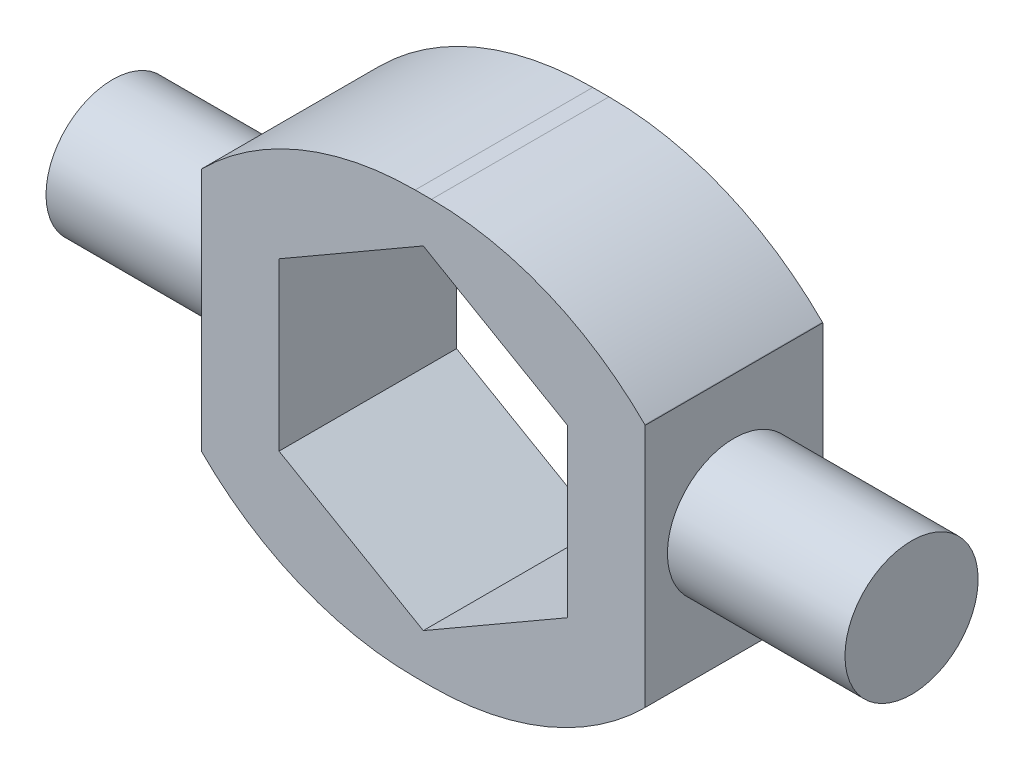
from build123d import *

# Parameters (mm, degrees)
SKETCH1_W           = 63.5
SKETCH1_H           = 60.360264722
BOSS_EXTRUDE1_DEPTH = 25.4
CHAMFER1_SIZE       = 12.7
SKETCH2_R           = 9.525
BOSS_EXTRUDE2_DEPTH = 25.4
FILLET1_R           = 43.18


with BuildPart() as part:
    # Sketch1 → Boss-Extrude1 (new body)
    with BuildSketch(Plane.XY):
        with Locations((31.75, 30.180132361)):
            Rectangle(SKETCH1_W, SKETCH1_H)
        Polygon((11.1125, 42.095198541), (11.1125, 18.26506618), (31.75, 6.35), (52.3875, 18.26506618), (52.3875, 42.095198541), (31.75, 54.010264722), align=None, mode=Mode.SUBTRACT)
    extrude(amount=BOSS_EXTRUDE1_DEPTH)

    # Chamfer1
    chamfer1_edges = [part.edges().sort_by_distance(p)[0] for p in [
        (0, 60.360264722, 12.7),
        (63.5, 60.360264722, 12.7),
        (63.5, 0, 12.7),
        (0, 0, 12.7),
    ]]
    chamfer(chamfer1_edges, length=CHAMFER1_SIZE)

    # Sketch2 → Boss-Extrude2 (add)
    with BuildSketch(Plane.ZY):
        with Locations((12.7, 30.180132361)):
            Circle(SKETCH2_R)
    boss_extrude2 = extrude(amount=BOSS_EXTRUDE2_DEPTH)

    # Mirror1: Boss-Extrude2 across plane
    add(boss_extrude2.mirror(Plane(origin=(31.75, 0, 0), x_dir=(0, 0, 1), z_dir=(1, 0, 0))))

    # Fillet1
    fillet1_edges = [part.edges().sort_by_distance(p)[0] for p in [
        (12.7, 60.360264722, 12.7),
        (50.8, 60.360264722, 12.7),
        (12.7, 0, 12.7),
        (50.8, 0, 12.7),
    ]]
    fillet(fillet1_edges, radius=FILLET1_R)


solid = part.part
